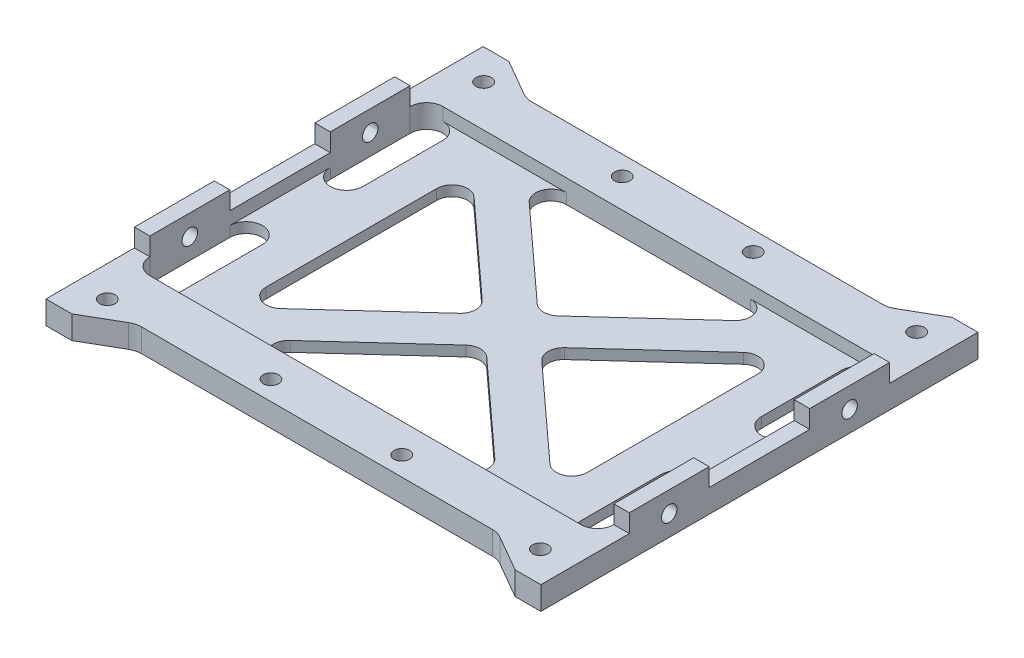
from build123d import *

# Parameters (mm, degrees)
SKETCH1_R           = 1.5
BOSS_EXTRUDE1_DEPTH = 2
SKETCH2_R           = 1.5
BOSS_EXTRUDE2_DEPTH = 2.5
BOSS_EXTRUDE3_START = -3
SKETCH3_W           = 15.5
SKETCH3_H           = 3.5
BOSS_EXTRUDE3_DEPTH = 3
SKETCH4_R           = 1.5
CUT_EXTRUDE1_DEPTH  = 5
CUT_EXTRUDE2_DEPTH  = 65.325422657


with BuildPart() as part:
    # Sketch1 → Boss-Extrude1 (new body)
    with BuildSketch(Plane(origin=(0, 0, 0), x_dir=(1, 0, 0), z_dir=(0, 1, 0))):
        with BuildLine():
            Line((-48, -42.4), (-43, -42.4))
            Line((-43, -42.4), (-36.009266938, -38.363898385))
            ThreePointArc((-36.009266938, -38.363898385), (-35.044543118, -37.964296695), (-34.009266938, -37.828))
            Line((-34.009266938, -37.828), (34.009266938, -37.828))
            ThreePointArc((34.009266938, -37.828), (35.044543118, -37.964296695), (36.009266938, -38.363898385))
            Line((36.009266938, -38.363898385), (43, -42.4))
            Line((43, -42.4), (48, -42.4))
            Line((48, -42.4), (48, 42.4))
            Line((48, 42.4), (43, 42.4))
            Line((43, 42.4), (36.009266938, 38.363898385))
            ThreePointArc((36.009266938, 38.363898385), (35.044543118, 37.964296695), (34.009266938, 37.828))
            Line((34.009266938, 37.828), (-34.009266938, 37.828))
            ThreePointArc((-34.009266938, 37.828), (-35.044543118, 37.964296695), (-36.009266938, 38.363898385))
            Line((-36.009266938, 38.363898385), (-43, 42.4))
            Line((-43, 42.4), (-48, 42.4))
            Line((-48, 42.4), (-48, -42.4))
        make_face()
        with Locations(Location((-12.7, -34.078, 0), (0, 0, 270))):
            Circle(SKETCH1_R, mode=Mode.SUBTRACT)
        with Locations(Location((12.7, -34.078, 0), (0, 0, 270))):
            Circle(SKETCH1_R, mode=Mode.SUBTRACT)
        with Locations(Location((-12.7, 34.078, 0), (0, 0, 270))):
            Circle(SKETCH1_R, mode=Mode.SUBTRACT)
        with Locations(Location((12.7, 34.078, 0), (0, 0, 270))):
            Circle(SKETCH1_R, mode=Mode.SUBTRACT)
        with Locations(Location((-42, 36.5, 0), (0, 0, 270))):
            Circle(SKETCH1_R, mode=Mode.SUBTRACT)
        with Locations(Location((42, 36.5, 0), (0, 0, 270))):
            Circle(SKETCH1_R, mode=Mode.SUBTRACT)
        with Locations(Location((42, -36.5, 0), (0, 0, 270))):
            Circle(SKETCH1_R, mode=Mode.SUBTRACT)
        with Locations(Location((-42, -36.5, 0), (0, 0, 270))):
            Circle(SKETCH1_R, mode=Mode.SUBTRACT)
        with BuildLine():
            Line((-38.65, 25.25), (-38.65, 9.75))
            ThreePointArc((-38.65, 9.75), (-41.825, 6.575), (-45, 9.75))
            Line((-45, 9.75), (-45, 25.25))
            ThreePointArc((-45, 25.25), (-41.825, 28.425), (-38.65, 25.25))
        make_face(mode=Mode.SUBTRACT)
        with BuildLine():
            Line((-38.65, -9.75), (-38.65, -25.25))
            ThreePointArc((-38.65, -25.25), (-41.825, -28.425), (-45, -25.25))
            Line((-45, -25.25), (-45, -9.75))
            ThreePointArc((-45, -9.75), (-41.825, -6.575), (-38.65, -9.75))
        make_face(mode=Mode.SUBTRACT)
        with BuildLine():
            Line((45, 25.25), (45, 9.75))
            ThreePointArc((45, 9.75), (41.825, 6.575), (38.65, 9.75))
            Line((38.65, 9.75), (38.65, 25.25))
            ThreePointArc((38.65, 25.25), (41.825, 28.425), (45, 25.25))
        make_face(mode=Mode.SUBTRACT)
        with BuildLine():
            Line((45, -9.75), (45, -25.25))
            ThreePointArc((45, -25.25), (41.825, -28.425), (38.65, -25.25))
            Line((38.65, -25.25), (38.65, -9.75))
            ThreePointArc((38.65, -9.75), (41.825, -6.575), (45, -9.75))
        make_face(mode=Mode.SUBTRACT)
    extrude(amount=BOSS_EXTRUDE1_DEPTH)

    # Sketch2 → Boss-Extrude2 (add)
    with BuildSketch(Plane(origin=(0, 2, 0), x_dir=(1, 0, 0), z_dir=(0, 1, 0))):
        with BuildLine():
            Line((48, -42.4), (48, 42.4))
            Line((48, 42.4), (43, 42.4))
            Line((43, 42.4), (36.009266938, 38.363898385))
            ThreePointArc((36.009266938, 38.363898385), (35.044543118, 37.964296695), (34.009266938, 37.828))
            Line((34.009266938, 37.828), (-34.009266938, 37.828))
            ThreePointArc((-34.009266938, 37.828), (-35.044543118, 37.964296695), (-36.009266938, 38.363898385))
            Line((-36.009266938, 38.363898385), (-43, 42.4))
            Line((-43, 42.4), (-48, 42.4))
            Line((-48, 42.4), (-48, -42.4))
            Line((-48, -42.4), (-43, -42.4))
            Line((-43, -42.4), (-36.009266938, -38.363898385))
            ThreePointArc((-36.009266938, -38.363898385), (-35.044543118, -37.964296695), (-34.009266938, -37.828))
            Line((-34.009266938, -37.828), (34.009266938, -37.828))
            ThreePointArc((34.009266938, -37.828), (35.044543118, -37.964296695), (36.009266938, -38.363898385))
            Line((36.009266938, -38.363898385), (43, -42.4))
            Line((43, -42.4), (48, -42.4))
        make_face()
        with Locations((-42, -36.5)):
            Circle(SKETCH2_R, mode=Mode.SUBTRACT)
        with Locations((-12.7, -34.078)):
            Circle(SKETCH2_R, mode=Mode.SUBTRACT)
        with Locations((12.7, -34.078)):
            Circle(SKETCH2_R, mode=Mode.SUBTRACT)
        with Locations((42, -36.5)):
            Circle(SKETCH2_R, mode=Mode.SUBTRACT)
        with Locations((-42, 36.5)):
            Circle(SKETCH2_R, mode=Mode.SUBTRACT)
        with Locations((-12.7, 34.078)):
            Circle(SKETCH2_R, mode=Mode.SUBTRACT)
        with BuildLine():
            Line((45, 9.75), (45, -9.75))
            Line((45, -9.75), (45, -25.25))
            ThreePointArc((45, -25.25), (44.07006403, -27.49506403), (41.825, -28.425))
            Line((41.825, -28.425), (-41.825, -28.425))
            ThreePointArc((-41.825, -28.425), (-44.07006403, -27.49506403), (-45, -25.25))
            Line((-45, -25.25), (-45, -9.75))
            Line((-45, -9.75), (-45, 9.75))
            Line((-45, 9.75), (-45, 25.25))
            ThreePointArc((-45, 25.25), (-44.07006403, 27.49506403), (-41.825, 28.425))
            Line((-41.825, 28.425), (41.825, 28.425))
            ThreePointArc((41.825, 28.425), (44.07006403, 27.49506403), (45, 25.25))
            Line((45, 25.25), (45, 9.75))
        make_face(mode=Mode.SUBTRACT)
        with Locations((12.7, 34.078)):
            Circle(SKETCH2_R, mode=Mode.SUBTRACT)
        with Locations((42, 36.5)):
            Circle(SKETCH2_R, mode=Mode.SUBTRACT)
    extrude(amount=BOSS_EXTRUDE2_DEPTH)

    # Sketch3 → Boss-Extrude3 (add)
    with BuildSketch(Plane(origin=(48, 0, 0), x_dir=(0, 0, -1), z_dir=(1, 0, 0)).offset(BOSS_EXTRUDE3_START)):
        with Locations((-17.5, 6.25)):
            Rectangle(SKETCH3_W, SKETCH3_H)
        with Locations((17.5, 6.25)):
            Rectangle(SKETCH3_W, SKETCH3_H)
    boss_extrude3 = extrude(amount=BOSS_EXTRUDE3_DEPTH)

    # Sketch4 → Cut-Extrude1 (cut)
    with BuildSketch(Plane(origin=(48, 0, 0), x_dir=(0, 0, -1), z_dir=(1, 0, 0))):
        with Locations((-17.5, 4)):
            Circle(SKETCH4_R)
        with Locations((17.5, 4)):
            Circle(SKETCH4_R)
    cut_extrude1 = extrude(amount=-CUT_EXTRUDE1_DEPTH, mode=Mode.SUBTRACT)

    # Mirror1: Boss-Extrude3, Cut-Extrude1 across plane
    add(boss_extrude3.mirror(Plane(origin=(0, 0, 0), x_dir=(0, 0, 1), z_dir=(1, 0, 0))))
    add(cut_extrude1.mirror(Plane(origin=(0, 0, 0), x_dir=(0, 0, 1), z_dir=(1, 0, 0))), mode=Mode.SUBTRACT)

    # Sketch5 → Cut-Extrude2 (cut, through all)
    with BuildSketch(Plane(origin=(0, 2, 0), x_dir=(1, 0, 0), z_dir=(0, 1, 0))):
        with BuildLine():
            Line((-26.127824556, -18.76552712), (-7.991792465, -2.216033952))
            ThreePointArc((-7.991792465, -2.216033952), (-7.013967909, 0), (-7.991792465, 2.216033952))
            Line((-7.991792465, 2.216033952), (-26.127824556, 18.76552712))
            ThreePointArc((-26.127824556, 18.76552712), (-29.361089111, 19.294172233), (-31.15, 16.549493168))
            Line((-31.15, 16.549493168), (-31.15, -16.549493168))
            ThreePointArc((-31.15, -16.549493168), (-29.361089111, -19.294172233), (-26.127824556, -18.76552712))
        make_face()
        with BuildLine():
            Line((19.87060859, 23.208966048), (2.022175444, 6.921912688))
            ThreePointArc((2.022175444, 6.921912688), (0, 6.137946639), (-2.022175444, 6.921912688))
            Line((-2.022175444, 6.921912688), (-19.87060859, 23.208966048))
            ThreePointArc((-19.87060859, 23.208966048), (-20.645583648, 26.509411856), (-17.848433147, 28.425))
            Line((-17.848433147, 28.425), (17.848433147, 28.425))
            ThreePointArc((17.848433147, 28.425), (20.645583648, 26.509411856), (19.87060859, 23.208966048))
        make_face()
        with BuildLine():
            Line((-19.87060859, -23.208966048), (-2.022175444, -6.921912688))
            ThreePointArc((-2.022175444, -6.921912688), (0, -6.137946639), (2.022175444, -6.921912688))
            Line((2.022175444, -6.921912688), (19.87060859, -23.208966048))
            ThreePointArc((19.87060859, -23.208966048), (20.645583648, -26.509411856), (17.848433147, -28.425))
            Line((17.848433147, -28.425), (-17.848433147, -28.425))
            ThreePointArc((-17.848433147, -28.425), (-20.645583648, -26.509411856), (-19.87060859, -23.208966048))
        make_face()
        with BuildLine():
            Line((7.991792465, 2.216033952), (26.127824556, 18.76552712))
            ThreePointArc((26.127824556, 18.76552712), (29.361089111, 19.294172233), (31.15, 16.549493168))
            Line((31.15, 16.549493168), (31.15, -16.549493168))
            ThreePointArc((31.15, -16.549493168), (29.361089111, -19.294172233), (26.127824556, -18.76552712))
            Line((26.127824556, -18.76552712), (7.991792465, -2.216033952))
            ThreePointArc((7.991792465, -2.216033952), (7.013967909, 0), (7.991792465, 2.216033952))
        make_face()
    extrude(amount=-CUT_EXTRUDE2_DEPTH, mode=Mode.SUBTRACT)


solid = part.part
